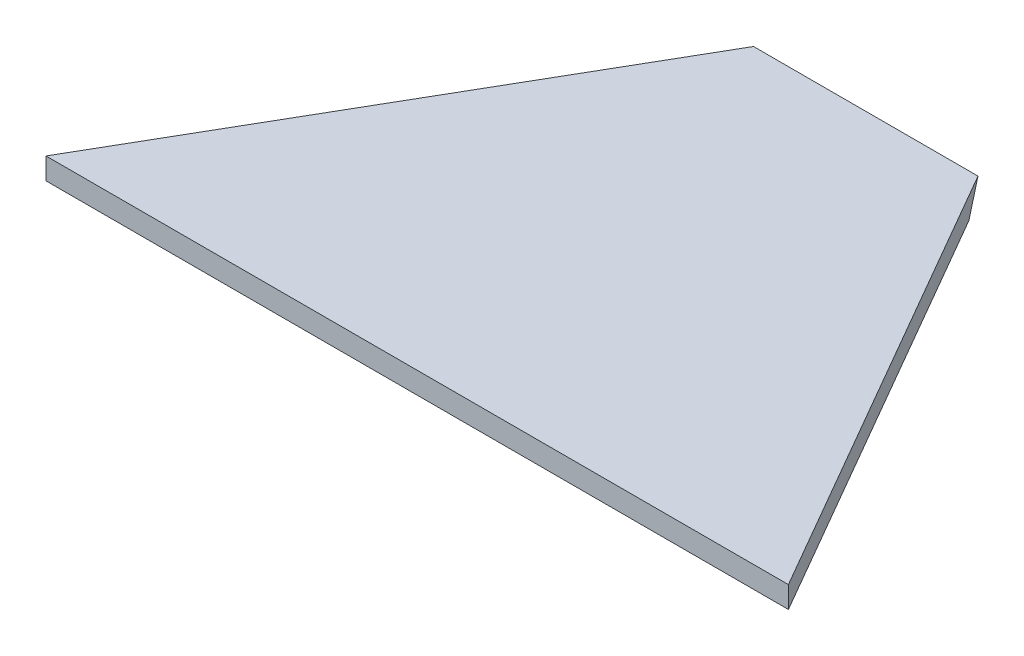
from build123d import *

# Parameters (mm, degrees)
BOSS_EXTRUDE1_DEPTH            = 6.35
CUT_EXTRUDE1_REACH             = 111.22
CUT_EXTRUDE1_DIRECTION_2_REACH = 111.22


with BuildPart() as part:
    # Sketch2 → Boss-Extrude1 (new body)
    with BuildSketch(Plane(origin=(0, 0, 0), x_dir=(1, 0, 0), z_dir=(0, 1, 0))):
        Polygon((-109.22, -85.086141102), (-33.02, 46.896130435), (33.02, 46.896130435), (109.22, -85.086141102), align=None)
    extrude(amount=BOSS_EXTRUDE1_DEPTH)

    # Sketch4 → Cut-Extrude1 (cut, up to next)
    with BuildSketch(Plane(origin=(0, 0, 0), x_dir=(0, 0, -1), z_dir=(1, 0, 0)), mode=Mode.PRIVATE) as cut_extrude1_sk1:
        Polygon((46.896130435, 6.35), (40.546130435, 0), (46.896130435, 0), align=None)
    cut_extrude1_tool1 = extrude(cut_extrude1_sk1.sketch, amount=-CUT_EXTRUDE1_REACH, mode=Mode.PRIVATE) & part.part
    add(cut_extrude1_tool1.solids().sort_by_distance((0, 2.116667, -44.779464))[0], mode=Mode.SUBTRACT)

    # Sketch4 → Cut-Extrude1 direction 2 (cut, up to next)
    with BuildSketch(Plane(origin=(0, 0, 0), x_dir=(0, 0, -1), z_dir=(1, 0, 0)), mode=Mode.PRIVATE) as cut_extrude1_direction_2_sk1:
        Polygon((46.896130435, 6.35), (40.546130435, 0), (46.896130435, 0), align=None)
    cut_extrude1_direction_2_tool1 = extrude(cut_extrude1_direction_2_sk1.sketch, amount=CUT_EXTRUDE1_DIRECTION_2_REACH, mode=Mode.PRIVATE) & part.part
    add(cut_extrude1_direction_2_tool1.solids().sort_by_distance((0, 2.116667, -44.779464))[0], mode=Mode.SUBTRACT)


solid = part.part
